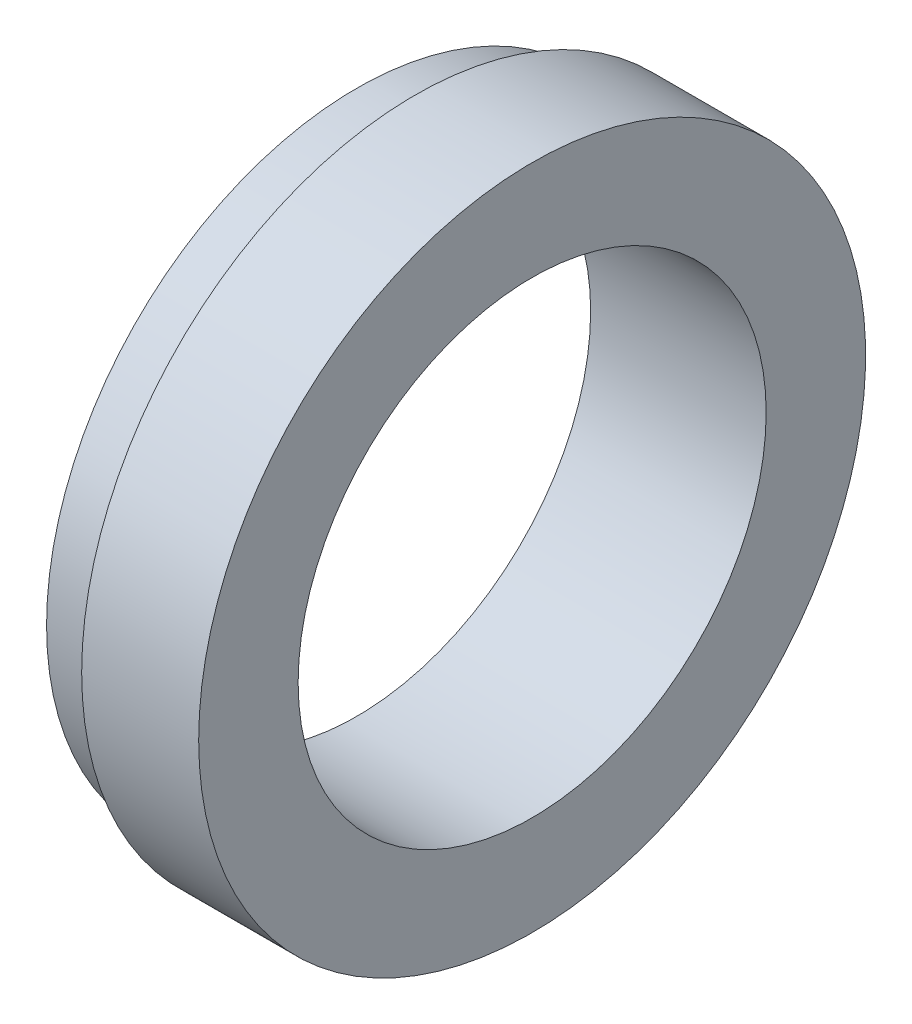
from build123d import *


with BuildPart() as part:
    # Эскиз1 → Повернуть1 (revolve)
    with BuildSketch(Plane.XY):
        Polygon((10, -20), (10, -28.5), (0, -28.5), (0, -26.5), (-5, -26.5), (-5, -20), align=None)
    revolve(axis=Axis((0, 0, 0), (1, 0, 0)))


solid = part.part
